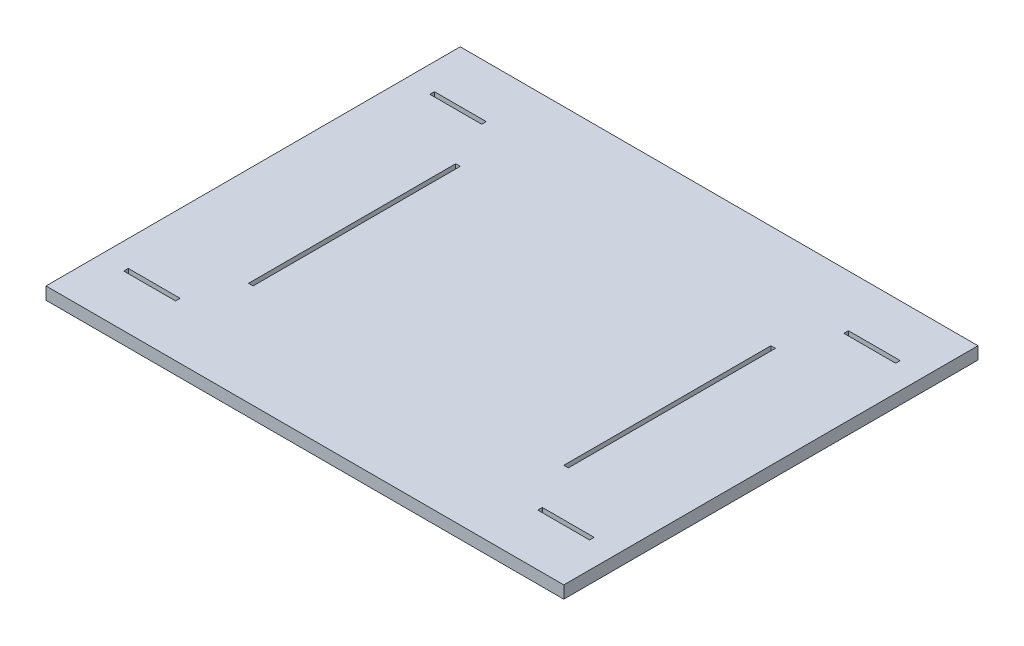
from build123d import *

# Parameters (mm, degrees)
SKETCH1_W                                  = 500
SKETCH1_H                                  = 400
BOSS_EXTRUDE1_DEPTH                        = 12
SKETCH2_W                                  = 4.4
SKETCH2_H                                  = 200
CUT_EXTRUDE1_DEPTH                         = 12
SKETCH5_W                                  = 50
SKETCH5_H                                  = 4.4
CUT_EXTRUDE2_DEPTH                         = 12
MIRROR5_AT_THE_SECOND_PLANE_COPY_1_SKETC_W = 50
MIRROR5_AT_THE_SECOND_PLANE_COPY_1_SKETC_H = 4.4
MIRROR5_AT_THE_SECOND_PLANE_COPY_1_DEPTH   = 12


with BuildPart() as part:
    # Sketch1 → Boss-Extrude1 (new body)
    with BuildSketch(Plane(origin=(0, 0, 0), x_dir=(1, 0, 0), z_dir=(0, 1, 0))):
        Rectangle(SKETCH1_W, SKETCH1_H)
    extrude(amount=BOSS_EXTRUDE1_DEPTH)

    # Sketch2 → Cut-Extrude1 (cut)
    with BuildSketch(Plane(origin=(0, 12, 0), x_dir=(1, 0, 0), z_dir=(0, 1, 0))):
        with Locations((-152.2, 0)):
            Rectangle(SKETCH2_W, SKETCH2_H)
    cut_extrude1 = extrude(amount=-CUT_EXTRUDE1_DEPTH, mode=Mode.SUBTRACT)

    # Mirror2: Cut-Extrude1 across plane
    add(cut_extrude1.mirror(Plane(origin=(0, 0, 0), x_dir=(0, 0, 1), z_dir=(1, 0, 0))), mode=Mode.SUBTRACT)

    # Sketch5 → Cut-Extrude2 (cut)
    with BuildSketch(Plane(origin=(0, 12, 0), x_dir=(1, 0, 0), z_dir=(0, 1, 0))):
        with Locations((-199.9, 147.8)):
            Rectangle(SKETCH5_W, SKETCH5_H)
    cut_extrude2 = extrude(amount=-CUT_EXTRUDE2_DEPTH, mode=Mode.SUBTRACT)

    # Mirror5: Cut-Extrude2 across plane
    add(cut_extrude2.mirror(Plane.XY), mode=Mode.SUBTRACT)

    # Mirror5 at the second plane: Cut-Extrude2 across plane
    add(cut_extrude2.mirror(Plane(origin=(0, 0, 0), x_dir=(0, 0, 1), z_dir=(1, 0, 0))), mode=Mode.SUBTRACT)

    # Mirror5 at the second plane copy 1 sketc → Mirror5 at the second plane copy 1 (cut)
    with BuildSketch(Plane(origin=(0, 12, 0), x_dir=(-1, 0, 0), z_dir=(0, 1, 0))):
        with Locations((-199.9, 147.8)):
            Rectangle(MIRROR5_AT_THE_SECOND_PLANE_COPY_1_SKETC_W, MIRROR5_AT_THE_SECOND_PLANE_COPY_1_SKETC_H)
    extrude(amount=-MIRROR5_AT_THE_SECOND_PLANE_COPY_1_DEPTH, mode=Mode.SUBTRACT)


solid = part.part
